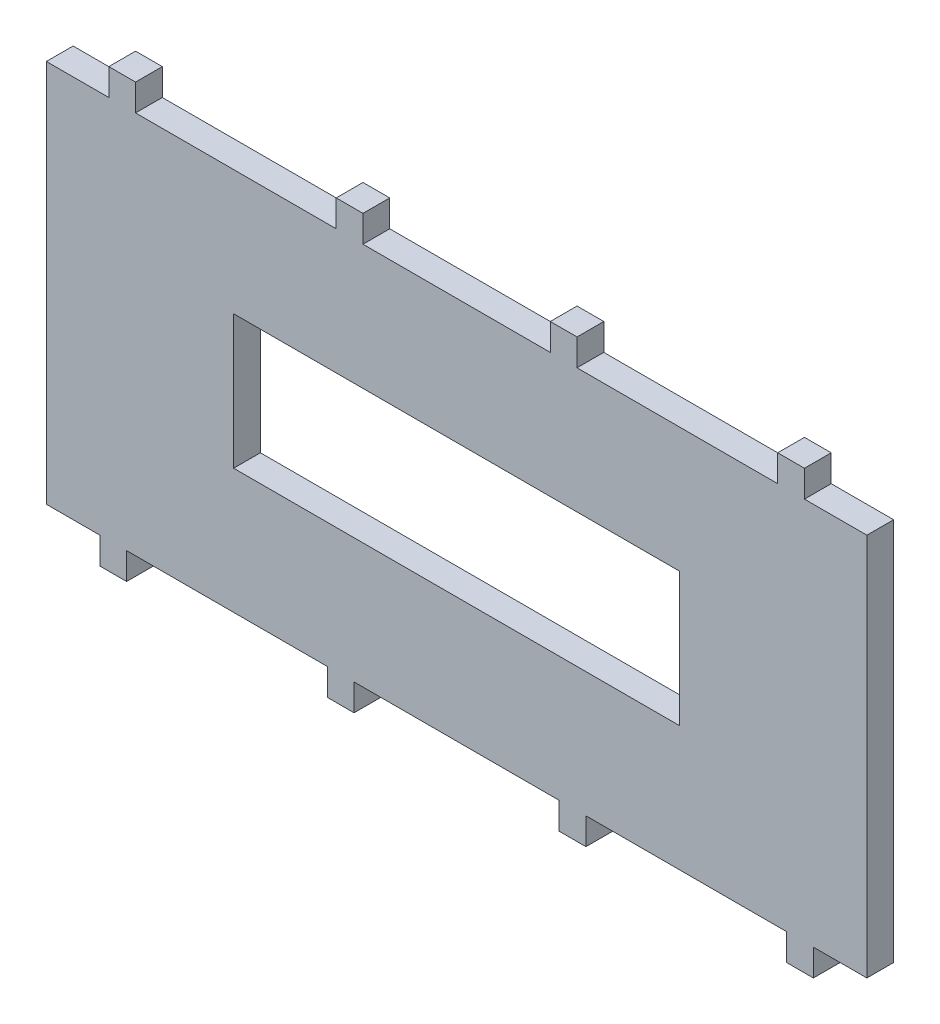
from build123d import *

# Parameters (mm, degrees)
SKETCH1_W           = 184
SKETCH1_H           = 86
BOSS_EXTRUDE1_DEPTH = 6
SKETCH2_W           = 6
SKETCH2_H           = 6
BOSS_EXTRUDE2_DEPTH = 6
SKETCH3_W           = 100
SKETCH3_H           = 30
CUT_EXTRUDE1_DEPTH  = 6


with BuildPart() as part:
    # Sketch1 → Boss-Extrude1 (new body)
    with BuildSketch(Plane.XY):
        with Locations((0, 43)):
            Rectangle(SKETCH1_W, SKETCH1_H)
    extrude(amount=BOSS_EXTRUDE1_DEPTH)

    # Sketch2 → Boss-Extrude2 (add)
    with BuildSketch(Plane.XY):
        with Locations((-77, -3)):
            Rectangle(SKETCH2_W, SKETCH2_H)
        with Locations((-26, -3)):
            Rectangle(SKETCH2_W, SKETCH2_H)
        with Locations((26, -3)):
            Rectangle(SKETCH2_W, SKETCH2_H)
        with Locations((77, -3)):
            Rectangle(SKETCH2_W, SKETCH2_H)
        with Locations((-75, 89)):
            Rectangle(SKETCH2_W, SKETCH2_H)
        with Locations((-24, 89)):
            Rectangle(SKETCH2_W, SKETCH2_H)
        with Locations((24, 89)):
            Rectangle(SKETCH2_W, SKETCH2_H)
        with Locations((75, 89)):
            Rectangle(SKETCH2_W, SKETCH2_H)
    extrude(amount=BOSS_EXTRUDE2_DEPTH)

    # Sketch3 → Cut-Extrude1 (cut)
    with BuildSketch(Plane.XY.offset(6)):
        with Locations((0, 43)):
            Rectangle(SKETCH3_W, SKETCH3_H)
    extrude(amount=-CUT_EXTRUDE1_DEPTH, mode=Mode.SUBTRACT)


solid = part.part
